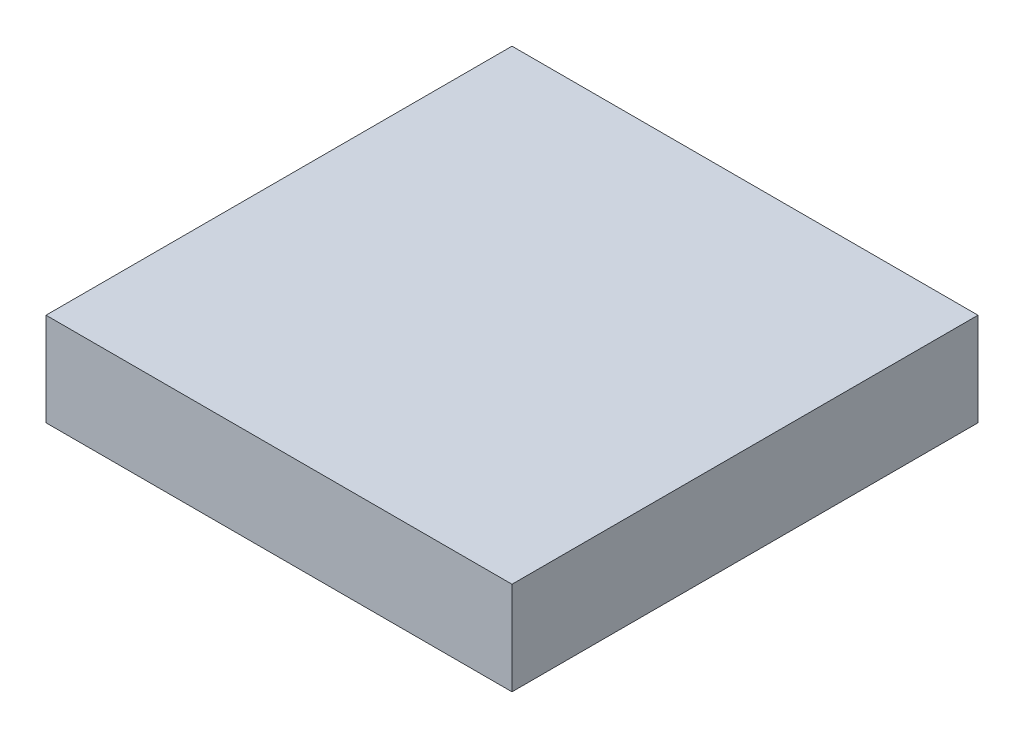
from build123d import *

# Parameters (mm, degrees)
SKETCH1_W           = 25.4
SKETCH1_H           = 25.4
BOSS_EXTRUDE1_DEPTH = 5.08


with BuildPart() as part:
    # Sketch1 → Boss-Extrude1 (new body)
    with BuildSketch(Plane(origin=(0, 0, 0), x_dir=(1, 0, 0), z_dir=(0, 1, 0))):
        Rectangle(SKETCH1_W, SKETCH1_H)
    extrude(amount=BOSS_EXTRUDE1_DEPTH)


solid = part.part
